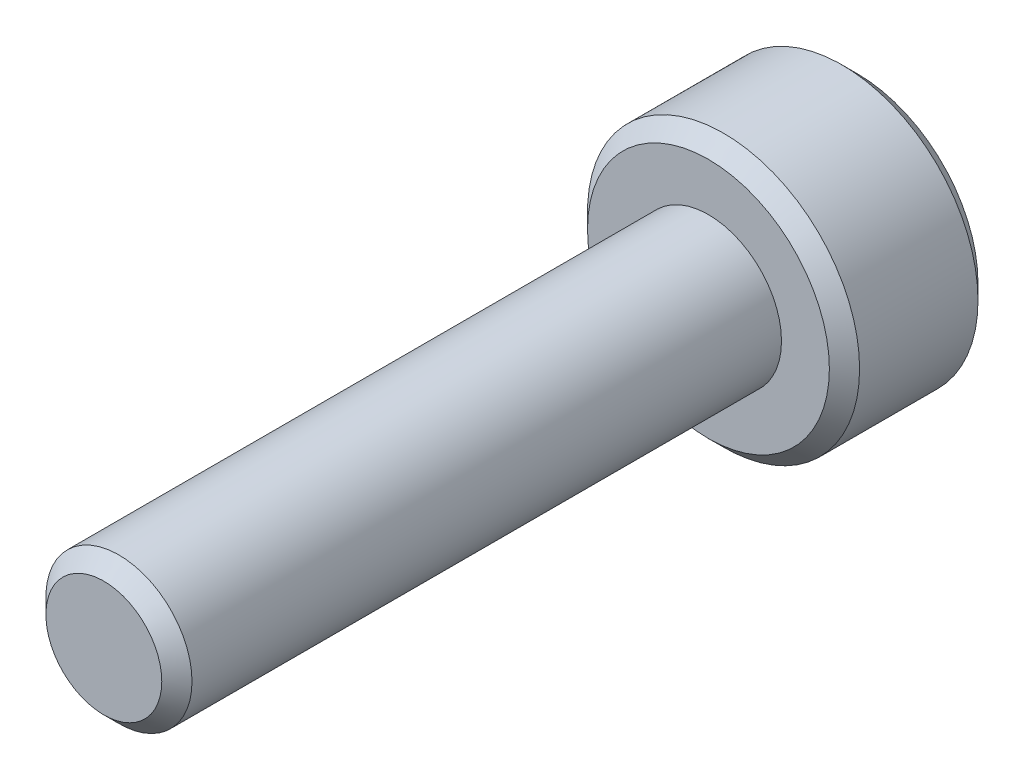
from build123d import *

# Parameters (mm, degrees)
SKIZZE1_R                       = 2.7
AUFSATZ_LINEAR_AUSTRAGEN1_DEPTH = 2.95
SKIZZE2_R                       = 1.45
AUFSATZ_LINEAR_AUSTRAGEN2_DEPTH = 12
FASE1_SIZE                      = 0.3
SCHNITT_LINEAR_AUSTRAGEN1_DEPTH = 2.5


with BuildPart() as part:
    # Skizze1 → Aufsatz-Linear austragen1 (new body)
    with BuildSketch(Plane.XY):
        Circle(SKIZZE1_R)
    extrude(amount=AUFSATZ_LINEAR_AUSTRAGEN1_DEPTH)

    # Skizze2 → Aufsatz-Linear austragen2 (add)
    with BuildSketch(Plane.XY.offset(2.95)):
        Circle(SKIZZE2_R)
    extrude(amount=AUFSATZ_LINEAR_AUSTRAGEN2_DEPTH)

    # Fase1
    fase1_edges = [part.edges().sort_by_distance(p)[0] for p in [
        (-2.7, 0, 0),
        (-2.7, 0, 2.95),
        (-1.45, 0, 14.95),
    ]]
    chamfer(fase1_edges, length=FASE1_SIZE)

    # Skizze3 → Schnitt-Linear austragen1 (cut)
    with BuildSketch(Plane(origin=(0, 0, 0), x_dir=(-1, 0, 0), z_dir=(0, 0, -1))):
        Polygon((1.25, 0.721687836), (0, 1.443375673), (-1.25, 0.721687836), (-1.25, -0.721687836), (0, -1.443375673), (1.25, -0.721687836), align=None)
    extrude(amount=-SCHNITT_LINEAR_AUSTRAGEN1_DEPTH, mode=Mode.SUBTRACT)


solid = part.part
